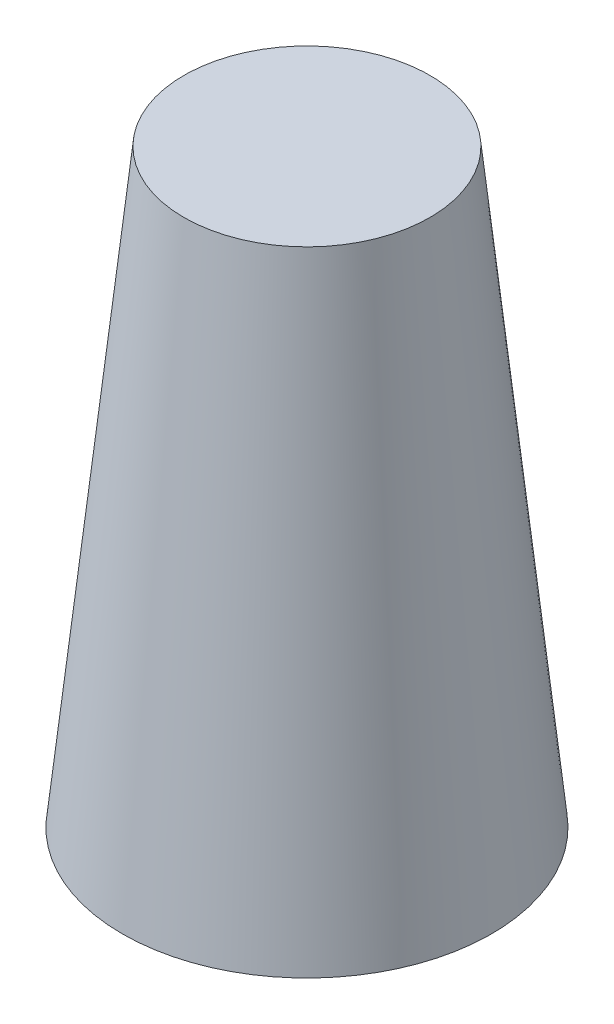
from build123d import *


with BuildPart() as part:
    # Sketch1 → Revolve1 (revolve)
    with BuildSketch(Plane.XY):
        Polygon((0, 115), (24, 115), (36, 0), (34.491855758, 0), (22.648377497, 113.5), (0, 113.5), align=None)
    revolve(axis=Axis((0, 55, 0), (0, -1, 0)))


solid = part.part
